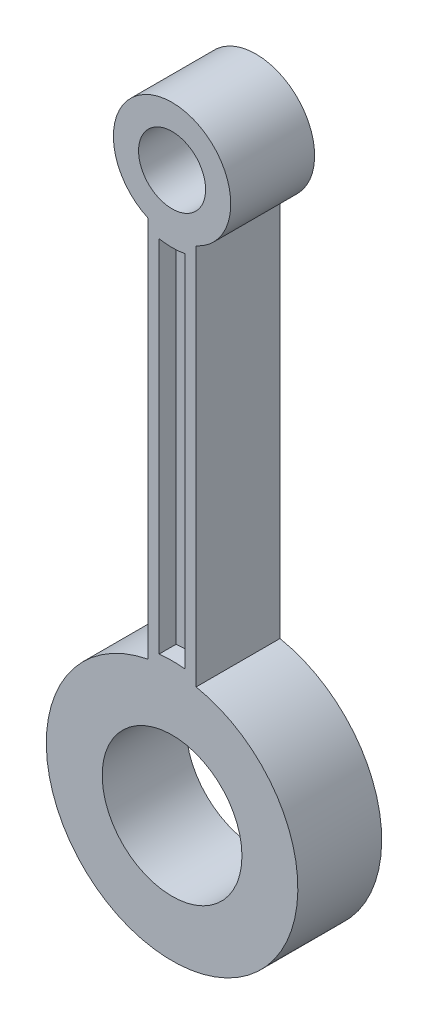
from build123d import *

# Parameters (mm, degrees)
SKETCH1_R           = 12.5
SKETCH1_R_2         = 6
BOSS_EXTRUDE2_DEPTH = 7.5
BOSS_EXTRUDE3_DEPTH = 4.5


with BuildPart() as part:
    # Sketch1 → Boss-Extrude2 (new body, symmetric)
    with BuildSketch(Plane.XY):
        with BuildLine():
            Line((2.01059306, -9.376516335), (2.01059306, 58.959050431))
            ThreePointArc((2.01059306, 58.959050431), (-2.28940694, 79.038194443), (-6.58940694, 58.959050431))
            Line((-6.58940694, 58.959050431), (-6.58940694, -9.376516335))
            ThreePointArc((-6.58940694, -9.376516335), (-2.28940694, -53.961805557), (2.01059306, -9.376516335))
        make_face()
        with Locations((-2.28940694, -31.461805557)):
            Circle(SKETCH1_R, mode=Mode.SUBTRACT)
        with Locations((-2.28940694, 68.538194443)):
            Circle(SKETCH1_R_2, mode=Mode.SUBTRACT)
        with BuildLine():
            Line((-4.58940694, 56.760673481), (-4.58940694, -7.572268098))
            ThreePointArc((-4.58940694, -7.572268098), (-2.28940694, -7.461805557), (0.01059306, -7.572268098))
            Line((0.01059306, -7.572268098), (0.01059306, 56.760673481))
            ThreePointArc((0.01059306, 56.760673481), (-2.28940694, 56.538194443), (-4.58940694, 56.760673481))
        make_face(mode=Mode.SUBTRACT)
    extrude(amount=BOSS_EXTRUDE2_DEPTH, both=True)

    # Sketch2 → Boss-Extrude3 (add, symmetric)
    with BuildSketch(Plane.XY):
        with BuildLine():
            Line((-4.58940694, 56.760673481), (-4.58940694, -7.572268098))
            ThreePointArc((-4.58940694, -7.572268098), (-2.28940694, -7.461805557), (0.01059306, -7.572268098))
            Line((0.01059306, -7.572268098), (0.01059306, 56.760673481))
            ThreePointArc((0.01059306, 56.760673481), (-2.28940694, 56.538194443), (-4.58940694, 56.760673481))
        make_face()
    extrude(amount=BOSS_EXTRUDE3_DEPTH, both=True)


solid = part.part
